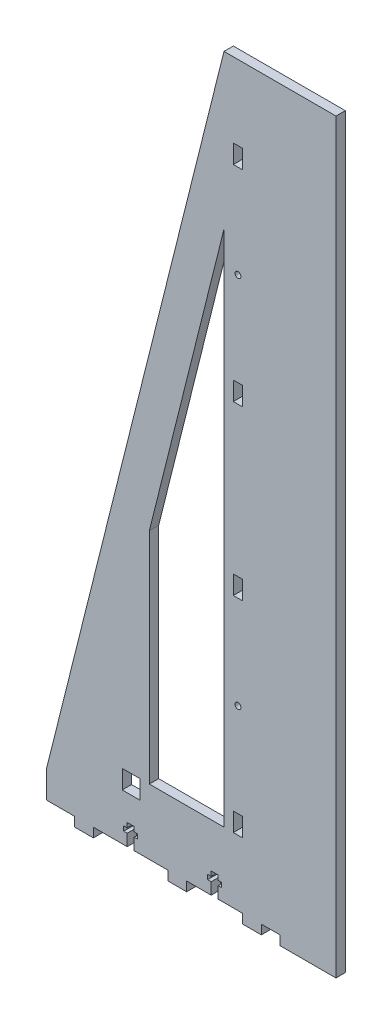
from build123d import *

# Parameters (mm, degrees)
BOSS_EXTRUDE1_DEPTH = 6.35
CUT_EXTRUDE1_DEPTH  = 6.35
SKETCH4_R           = 2
SKETCH4_W           = 6.35
SKETCH4_H           = 12.7
CUT_EXTRUDE5_DEPTH  = 6.35
SKETCH6_W           = 6.35
SKETCH6_H           = 12.7
CUT_EXTRUDE6_DEPTH  = 6.35
CUT_EXTRUDE7_DEPTH  = 6.35
SKETCH5_W           = 6.35
SKETCH5_H           = 12.7
CUT_EXTRUDE4_DEPTH  = 6.35


with BuildPart() as part:
    # Sketch1 → Boss-Extrude1 (new body)
    with BuildSketch(Plane.XY):
        Polygon((190.5, 508), (120.65, 508), (0, 25.4), (0, 6.35), (19.05, 6.35), (19.05, 0), (31.75, 0), (31.75, 6.35), (82.55, 6.35), (82.55, 0), (95.25, 0), (95.25, 6.35), (133.35, 6.35), (133.35, 0), (146.05, 0), (146.05, 6.35), (158.75, 6.35), (158.75, 0), (190.5, 0), (196.85, 0), (196.85, 508), align=None)
        Polygon((120.65, 50.8), (120.65, 403.273117109), (82.55, 250.873117109), (82.55, 50.8), align=None, mode=Mode.SUBTRACT)
    extrude(amount=BOSS_EXTRUDE1_DEPTH)

    # Sketch2 → Cut-Extrude1 (cut)
    with BuildSketch(Plane.XY.offset(6.35)):
        Polygon((59.53125, 6.35), (54.76875, 6.35), (54.76875, 14.2875), (52.3875, 14.2875), (52.3875, 17.4625), (54.76875, 17.4625), (54.76875, 20.6375), (59.53125, 20.6375), (59.53125, 17.4625), (61.9125, 17.4625), (61.9125, 14.2875), (59.53125, 14.2875), align=None)
        Polygon((116.68125, 6.35), (111.91875, 6.35), (111.91875, 14.2875), (109.5375, 14.2875), (109.5375, 17.4625), (111.91875, 17.4625), (111.91875, 20.6375), (116.68125, 20.6375), (116.68125, 17.4625), (119.0625, 17.4625), (119.0625, 14.2875), (116.68125, 14.2875), align=None)
    extrude(amount=-CUT_EXTRUDE1_DEPTH, mode=Mode.SUBTRACT)

    # Sketch4 → Cut-Extrude5 (cut)
    with BuildSketch(Plane.XY.offset(6.35)):
        with Locations((130.175, 127)):
            Circle(SKETCH4_R)
        with Locations((130.175, 381)):
            Circle(SKETCH4_R)
        with Locations((130.175, 196.85)):
            Rectangle(SKETCH4_W, SKETCH4_H)
        with Locations((130.175, 57.15)):
            Rectangle(SKETCH4_W, SKETCH4_H)
        with Locations((130.175, 450.85)):
            Rectangle(SKETCH4_W, SKETCH4_H)
        with Locations((130.175, 311.15)):
            Rectangle(SKETCH4_W, SKETCH4_H)
    extrude(amount=-CUT_EXTRUDE5_DEPTH, mode=Mode.SUBTRACT)

    # Sketch6 → Cut-Extrude6 (cut)
    with BuildSketch(Plane.XY.offset(6.35)):
        with Locations((60.325, 44.45)):
            Rectangle(SKETCH6_W, SKETCH6_H)
    extrude(amount=-CUT_EXTRUDE6_DEPTH, mode=Mode.SUBTRACT)

    # Sketch7 → Cut-Extrude7 (cut)
    with BuildSketch(Plane.XY.offset(6.35)):
        Polygon((82.55, 50.8), (69.85, 50.8), (69.85, 200.073117109), (82.55, 250.873117109), align=None)
    extrude(amount=-CUT_EXTRUDE7_DEPTH, mode=Mode.SUBTRACT)

    # Sketch5 → Cut-Extrude4 (cut)
    with BuildSketch(Plane.XY.offset(6.35)):
        with Locations((54.590058309, 44.45)):
            Rectangle(SKETCH5_W, SKETCH5_H)
    extrude(amount=-CUT_EXTRUDE4_DEPTH, mode=Mode.SUBTRACT)


solid = part.part
